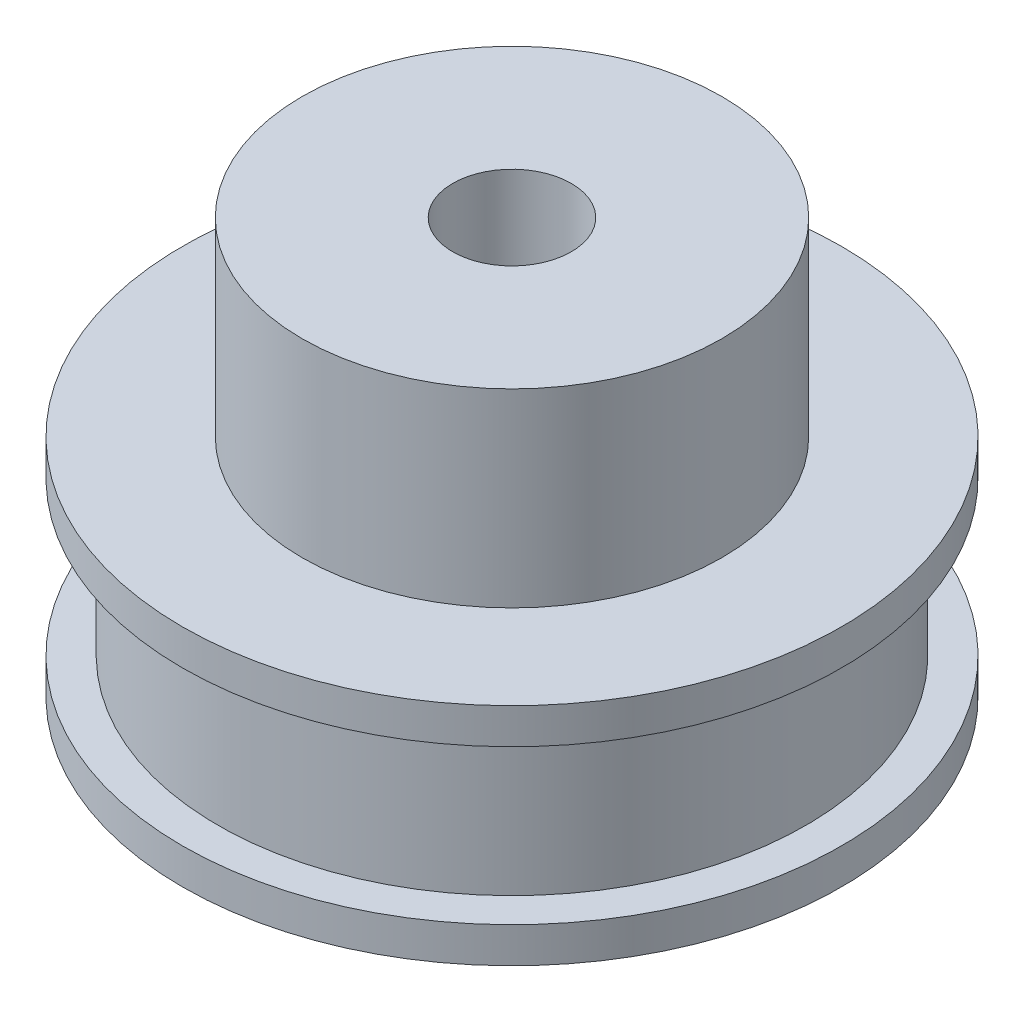
from build123d import *


with BuildPart() as part:
    # Esquisse1 → Révolution1 (revolve)
    with BuildSketch(Plane.XY):
        Polygon((2.5, 0), (13.9, 0), (13.9, 1.5), (12.4, 1.5), (12.4, 8), (13.9, 8), (13.9, 9.5), (8.85, 9.5), (8.85, 17.5), (2.5, 17.5), align=None)
    revolve(axis=Axis((0, 0, 0), (0, 1, 0)))


solid = part.part
